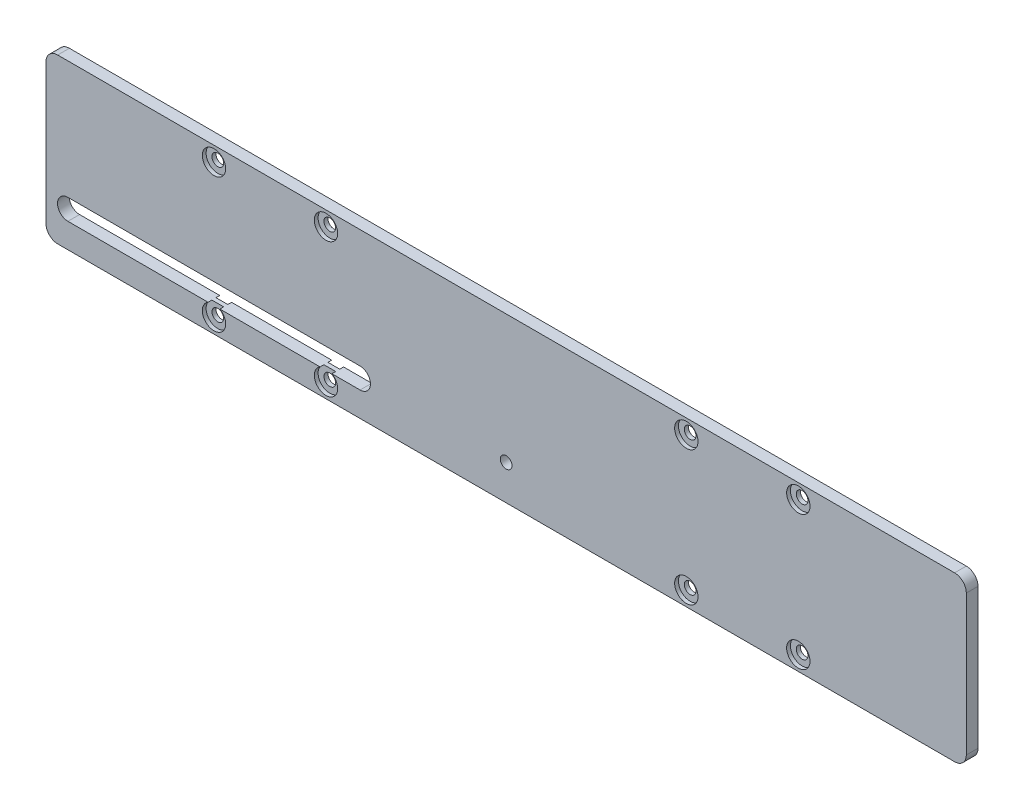
from build123d import *

# Parameters (mm, degrees)
SKETCH_1_R          = 2
EXTRUDE_1_DEPTH     = 4
SKETCH_2_R          = 4
CUT_EXTRUDE_1_DEPTH = 1.3
SKETCH_3_R          = 2
CUT_EXTRUDE_2_DEPTH = 10
SKETCH_5_R          = 4
CUT_EXTRUDE_4_DEPTH = 1.3


with BuildPart() as part:
    # 草图1 → 凸台-拉伸1 (new body)
    with BuildSketch(Plane.XY):
        with BuildLine():
            Line((153.5, -28), (-153.5, -28))
            ThreePointArc((-153.5, -28), (-156.328427125, -26.828427125), (-157.5, -24))
            Line((-157.5, -24), (-157.5, 24))
            ThreePointArc((-157.5, 24), (-156.328427125, 26.828427125), (-153.5, 28))
            Line((-153.5, 28), (153.5, 28))
            ThreePointArc((153.5, 28), (156.328427125, 26.828427125), (157.5, 24))
            Line((157.5, 24), (157.5, -24))
            ThreePointArc((157.5, -24), (156.328427125, -26.828427125), (153.5, -28))
        make_face()
        with Locations((-100, 23)):
            Circle(SKETCH_1_R, mode=Mode.SUBTRACT)
        with Locations((-61.67, 23)):
            Circle(SKETCH_1_R, mode=Mode.SUBTRACT)
        with Locations((-100, -23)):
            Circle(SKETCH_1_R, mode=Mode.SUBTRACT)
        with Locations((-61.67, -23)):
            Circle(SKETCH_1_R, mode=Mode.SUBTRACT)
        with Locations((100, -23)):
            Circle(SKETCH_1_R, mode=Mode.SUBTRACT)
        with Locations((61.67, -23)):
            Circle(SKETCH_1_R, mode=Mode.SUBTRACT)
        with Locations((61.67, 23)):
            Circle(SKETCH_1_R, mode=Mode.SUBTRACT)
        with Locations((100, 23)):
            Circle(SKETCH_1_R, mode=Mode.SUBTRACT)
        with BuildLine():
            Line((-150, -12.45), (-50, -12.45))
            ThreePointArc((-50, -12.45), (-46.45, -16), (-50, -19.55))
            Line((-50, -19.55), (-150, -19.55))
            ThreePointArc((-150, -19.55), (-153.55, -16), (-150, -12.45))
        make_face(mode=Mode.SUBTRACT)
    extrude(amount=EXTRUDE_1_DEPTH)

    # 草图2 → 切除-拉伸1 (cut)
    with BuildSketch(Plane.XY.offset(4)):
        with Locations((-100, 23)):
            Circle(SKETCH_2_R)
        with Locations((-61.67, 23)):
            Circle(SKETCH_2_R)
        with Locations((-100, -23)):
            Circle(SKETCH_2_R)
        with Locations((-61.67, -23)):
            Circle(SKETCH_2_R)
        with Locations((61.67, -23)):
            Circle(SKETCH_2_R)
        with Locations((100, -23)):
            Circle(SKETCH_2_R)
        with Locations((61.67, 23)):
            Circle(SKETCH_2_R)
        with Locations((100, 23)):
            Circle(SKETCH_2_R)
    extrude(amount=-CUT_EXTRUDE_1_DEPTH, mode=Mode.SUBTRACT)

    # 草图3 → 切除-拉伸2 (cut)
    with BuildSketch(Plane.XY.offset(4)):
        with Locations((0, -16)):
            Circle(SKETCH_3_R)
    extrude(amount=-CUT_EXTRUDE_2_DEPTH, mode=Mode.SUBTRACT)

    # 草图5 → 切除-拉伸4 (cut)
    with BuildSketch(Plane(origin=(0, 0, 0), x_dir=(-1, 0, 0), z_dir=(0, 0, -1))):
        with Locations((-100, -23)):
            Circle(SKETCH_5_R)
        with Locations((-61.67, -23)):
            Circle(SKETCH_5_R)
        with Locations((61.67, -23)):
            Circle(SKETCH_5_R)
        with Locations((100, -23)):
            Circle(SKETCH_5_R)
        with Locations((100, 23)):
            Circle(SKETCH_5_R)
        with Locations((61.67, 23)):
            Circle(SKETCH_5_R)
        with Locations((-61.67, 23)):
            Circle(SKETCH_5_R)
        with Locations((-100, 23)):
            Circle(SKETCH_5_R)
    extrude(amount=-CUT_EXTRUDE_4_DEPTH, mode=Mode.SUBTRACT)


solid = part.part
